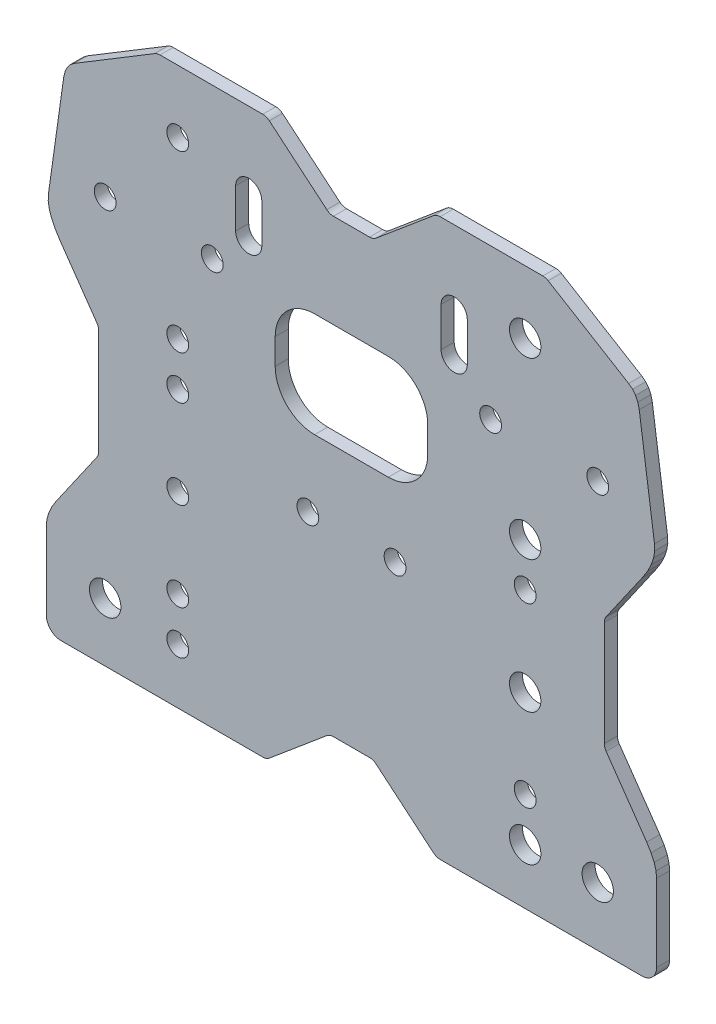
from build123d import *

# Parameters (mm, degrees)
MODEL_R             = 3.6
MODEL_R_2           = 2.5
BOSS_EXTRUDE1_DEPTH = 3


with BuildPart() as part:
    # Model → Boss-Extrude1 (new body)
    with BuildSketch(Plane.XY):
        with BuildLine():
            Line((-63.589037408, 104.045286478), (-64.491971364, 103.346418738))
            Line((-64.491971364, 103.346418738), (-65.195294282, 102.464131076))
            Line((-65.195294282, 102.464131076), (-65.706925279, 101.376095796))
            Line((-65.706925279, 101.376095796), (-66.01810151, 100.051055017))
            Line((-66.01810151, 100.051055017), (-69.517848709, 75.149059762))
            Line((-69.517848709, 75.149059762), (-69.565467008, 73.768185024))
            Line((-69.565467008, 73.768185024), (-69.321374593, 72.25214776))
            Line((-69.321374593, 72.25214776), (-68.771556944, 70.621505836))
            Line((-68.771556944, 70.621505836), (-67.922379623, 68.902975774))
            Line((-67.922379623, 68.902975774), (-66.786009136, 67.108706641))
            Line((-66.786009136, 67.108706641), (-58.427898105, 55.121080623))
            ThreePointArc((-58.427898105, 55.121080623), (-58.113658938, 54.481447327), (-58.0056, 53.777032482))
            Line((-58.0056, 53.777032482), (-58.0056, 29.705859287))
            ThreePointArc((-58.0056, 29.705859287), (-58.113493434, 29.001971409), (-58.427266507, 28.362717471))
            Line((-58.427266507, 28.362717471), (-67.733176699, 15.002327604))
            Line((-67.733176699, 15.002327604), (-68.737483208, 13.38044762))
            Line((-68.737483208, 13.38044762), (-69.450197862, 11.816899792))
            Line((-69.450197862, 11.816899792), (-69.867580727, 10.329866757))
            Line((-69.867580727, 10.329866757), (-70, 8.951275064))
            Line((-70, 8.951275064), (-70, -8.799924936))
            ThreePointArc((-70, -8.799924936), (-69.01608381, -11.175308746), (-66.6407, -12.159224936))
            Line((-66.6407, -12.159224936), (-20.346130051, -12.159224936))
            ThreePointArc((-20.346130051, -12.159224936), (-19.542382714, -12.017502594), (-18.835579168, -11.609429377))
            Line((-18.835579168, -11.609429377), (-5.655220832, -0.549795559))
            ThreePointArc((-5.655220832, -0.549795559), (-4.948417286, -0.141722341), (-4.144669949, 0))
            Line((-4.144669949, 0), (4.144669949, 0))
            ThreePointArc((4.144669949, 0), (4.948417286, -0.141722341), (5.655220832, -0.549795559))
            Line((5.655220832, -0.549795559), (18.835579168, -11.609429377))
            ThreePointArc((18.835579168, -11.609429377), (19.542382714, -12.017502594), (20.346130051, -12.159224936))
            Line((20.346130051, -12.159224936), (66.64, -12.159224936))
            ThreePointArc((66.64, -12.159224936), (69.015878785, -11.17510372), (70, -8.799224936))
            Line((70, -8.799224936), (70, 8.951275064))
            Line((70, 8.951275064), (69.867655237, 10.329854089))
            Line((69.867655237, 10.329854089), (69.450510447, 11.816864236))
            Line((69.450510447, 11.816864236), (68.738189425, 13.380413155))
            Line((68.738189425, 13.380413155), (67.734411359, 15.002327604))
            Line((67.734411359, 15.002327604), (58.431323409, 28.365944307))
            ThreePointArc((58.431323409, 28.365944307), (58.117803534, 29.004991954), (58.01, 29.708593408))
            Line((58.01, 29.708593408), (58.01, 53.780426534))
            ThreePointArc((58.01, 53.780426534), (58.11796888, 54.484554688), (58.431954432, 55.123981627))
            Line((58.431954432, 55.123981627), (66.78348855, 67.108706641))
            Line((66.78348855, 67.108706641), (67.921135722, 68.90552929))
            Line((67.921135722, 68.90552929), (68.770985107, 70.624910502))
            Line((68.770985107, 70.624910502), (69.321132211, 72.254429785))
            Line((69.321132211, 72.254429785), (69.565833124, 73.768624559))
            Line((69.565833124, 73.768624559), (69.518710346, 75.149059762))
            Line((69.518710346, 75.149059762), (66.018963147, 100.051055017))
            Line((66.018963147, 100.051055017), (65.69880853, 101.401637743))
            Line((65.69880853, 101.401637743), (65.172247364, 102.501733058))
            Line((65.172247364, 102.501733058), (64.474805148, 103.363406486))
            Line((64.474805148, 103.363406486), (63.589037408, 104.045286478))
            Line((63.589037408, 104.045286478), (45.129929366, 115.221048558))
            ThreePointArc((45.129929366, 115.221048558), (44.544648343, 115.474250568), (43.912842483, 115.560775065))
            Line((43.912842483, 115.560775065), (20.346130051, 115.560775065))
            ThreePointArc((20.346130051, 115.560775065), (19.542382714, 115.419052723), (18.835579168, 115.010979506))
            Line((18.835579168, 115.010979506), (5.655220832, 103.951345688))
            ThreePointArc((5.655220832, 103.951345688), (4.948417286, 103.54327247), (4.144669949, 103.401550129))
            Line((4.144669949, 103.401550129), (-4.144669949, 103.401550129))
            ThreePointArc((-4.144669949, 103.401550129), (-4.948417286, 103.54327247), (-5.655220832, 103.951345688))
            Line((-5.655220832, 103.951345688), (-18.835579168, 115.010979506))
            ThreePointArc((-18.835579168, 115.010979506), (-19.542382714, 115.419052723), (-20.346130051, 115.560775065))
            Line((-20.346130051, 115.560775065), (-43.912842483, 115.560775065))
            ThreePointArc((-43.912842483, 115.560775065), (-44.544648343, 115.474250568), (-45.129929366, 115.221048558))
            Line((-45.129929366, 115.221048558), (-63.589037408, 104.045286478))
        make_face()
        with Locations((-56.5, 1.360775064)):
            Circle(MODEL_R, mode=Mode.SUBTRACT)
        with Locations((-10, 41.740775065)):
            Circle(MODEL_R_2, mode=Mode.SUBTRACT)
        with Locations((-39.85, 0.522775064)):
            Circle(MODEL_R_2, mode=Mode.SUBTRACT)
        with Locations((-39.85, 10.522775064)):
            Circle(MODEL_R_2, mode=Mode.SUBTRACT)
        with Locations((-39.85, 30.842775065)):
            Circle(MODEL_R_2, mode=Mode.SUBTRACT)
        with Locations((-39.85, 51.162775065)):
            Circle(MODEL_R_2, mode=Mode.SUBTRACT)
        with Locations((-31.925, 81.060775064)):
            Circle(MODEL_R_2, mode=Mode.SUBTRACT)
        with Locations((-39.85, 61.162775065)):
            Circle(MODEL_R_2, mode=Mode.SUBTRACT)
        with Locations((-39.85, 101.162775064)):
            Circle(MODEL_R_2, mode=Mode.SUBTRACT)
        with Locations((-56.5, 81.060775064)):
            Circle(MODEL_R_2, mode=Mode.SUBTRACT)
        with Locations((39.85, 0.522775064)):
            Circle(MODEL_R, mode=Mode.SUBTRACT)
        with Locations((39.85, 30.842775065)):
            Circle(MODEL_R, mode=Mode.SUBTRACT)
        with Locations((56.5, 1.360775064)):
            Circle(MODEL_R, mode=Mode.SUBTRACT)
        with Locations((10, 41.740775065)):
            Circle(MODEL_R_2, mode=Mode.SUBTRACT)
        with Locations((39.85, 10.522775064)):
            Circle(MODEL_R_2, mode=Mode.SUBTRACT)
        with Locations((39.85, 51.162775065)):
            Circle(MODEL_R_2, mode=Mode.SUBTRACT)
        with Locations((39.85, 61.162775065)):
            Circle(MODEL_R, mode=Mode.SUBTRACT)
        with Locations((39.85, 101.162775064)):
            Circle(MODEL_R, mode=Mode.SUBTRACT)
        with Locations((31.925, 81.060775064)):
            Circle(MODEL_R_2, mode=Mode.SUBTRACT)
        with Locations((56.5, 81.060775064)):
            Circle(MODEL_R_2, mode=Mode.SUBTRACT)
        with BuildLine():
            Line((-26.57, 98.240775065), (-26.57, 89.240775065))
            ThreePointArc((-26.57, 89.240775065), (-23.57, 86.240775065), (-20.57, 89.240775065))
            Line((-20.57, 89.240775065), (-20.57, 98.240775065))
            ThreePointArc((-20.57, 98.240775065), (-23.57, 101.240775065), (-26.57, 98.240775065))
        make_face(mode=Mode.SUBTRACT)
        with BuildLine():
            Line((-17.5, 72.80015), (-17.5, 66.89985))
            ThreePointArc((-17.5, 66.89985), (-14.849360304, 60.500639696), (-8.45015, 57.85))
            Line((-8.45015, 57.85), (8.45015, 57.85))
            ThreePointArc((8.45015, 57.85), (14.849360304, 60.500639696), (17.5, 66.89985))
            Line((17.5, 66.89985), (17.5, 72.80015))
            ThreePointArc((17.5, 72.80015), (14.849360304, 79.199360304), (8.45015, 81.85))
            Line((8.45015, 81.85), (-8.45015, 81.85))
            ThreePointArc((-8.45015, 81.85), (-14.849360304, 79.199360304), (-17.5, 72.80015))
        make_face(mode=Mode.SUBTRACT)
        with BuildLine():
            Line((20.57, 98.240775065), (20.57, 89.240775065))
            ThreePointArc((20.57, 89.240775065), (23.57, 86.240775065), (26.57, 89.240775065))
            Line((26.57, 89.240775065), (26.57, 98.240775065))
            ThreePointArc((26.57, 98.240775065), (23.57, 101.240775065), (20.57, 98.240775065))
        make_face(mode=Mode.SUBTRACT)
    extrude(amount=BOSS_EXTRUDE1_DEPTH)


solid = part.part
